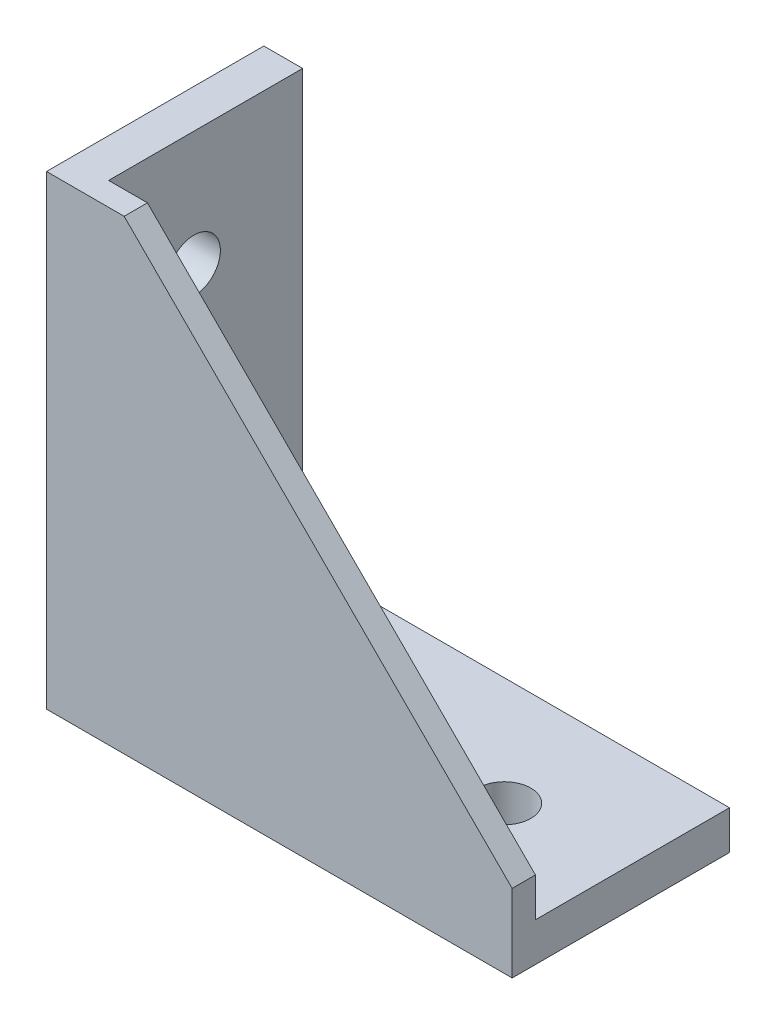
from build123d import *

# Parameters (mm, degrees)
EXTRUDE_1_DEPTH     = 14
EXTRUDE_2_DEPTH     = 3
SKETCH_3_R          = 3.4
CUT_EXTRUDE_1_DEPTH = 6
SKETCH_4_W          = 2.5
SKETCH_4_H          = 8
EXTRUDE_3_DEPTH     = 2.5


with BuildPart() as part:
    # Эскиз1 → Бобышка-Вытянуть1 (new body, symmetric)
    with BuildSketch(Plane.XY):
        Polygon((0, 60), (0, 0), (60, 0), (60, 5), (5, 5), (5, 60), align=None)
    extrude(amount=EXTRUDE_1_DEPTH, both=True)

    # Эскиз2 → Бобышка-Вытянуть2 (add)
    with BuildSketch(Plane.XY.offset(14)):
        Polygon((60, 5), (5, 5), (5, 60), (10, 60), (60, 10), align=None)
    extrude(amount=-EXTRUDE_2_DEPTH)

    # Эскиз3 → Вырез-Вытянуть1 (cut, through all)
    with BuildSketch(Plane(origin=(0, 5, 0), x_dir=(1, 0, 0), z_dir=(0, 1, 0))):
        with Locations(Location((45, 0, 0), (0, 0, 270))):  # turned: the seam where the file's is
            Circle(SKETCH_3_R)
        with BuildLine():
            Line((18, 3.4), (31.5, 3.4))
            ThreePointArc((31.5, 3.4), (34.9, 0), (31.5, -3.4))
            Line((31.5, -3.4), (18, -3.4))
            ThreePointArc((18, -3.4), (14.6, 0), (18, 3.4))
        make_face()
    cut_extrude_1 = extrude(amount=-CUT_EXTRUDE_1_DEPTH, mode=Mode.SUBTRACT)

    # Эскиз4 → Бобышка-Вытянуть3 (add)
    with BuildSketch(Plane.XZ):
        with Locations((4.25, 0)):
            Rectangle(SKETCH_4_W, SKETCH_4_H)
        with Locations((55.75, 0)):
            Rectangle(SKETCH_4_W, SKETCH_4_H)
    extrude_3 = extrude(amount=EXTRUDE_3_DEPTH)

    # Зеркальное отражение3: Вырез-Вытянуть1, Бобышка-Вытянуть3 across plane
    add(cut_extrude_1.mirror(Plane(origin=(0, 0, 0), x_dir=(0, 0, 1), z_dir=(-0.707106781, 0.707106781, 0))), mode=Mode.SUBTRACT)
    add(extrude_3.mirror(Plane(origin=(0, 0, 0), x_dir=(0, 0, 1), z_dir=(-0.707106781, 0.707106781, 0))))


solid = part.part
